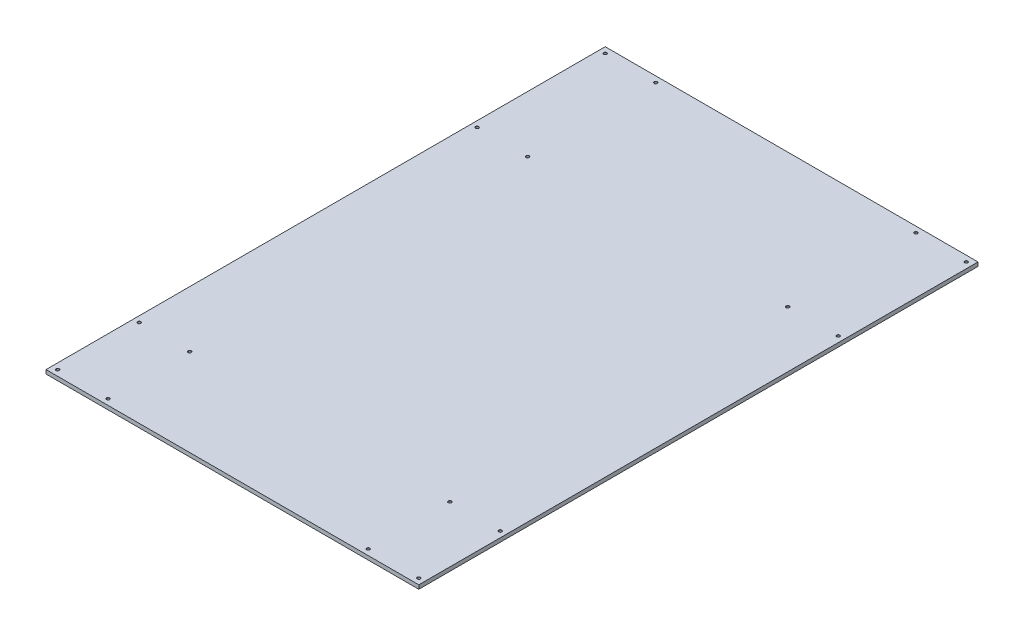
from build123d import *

# Parameters (mm, degrees)
SKETCH1_W                                 = 1219.2
SKETCH1_H                                 = 1828.8
BOSS_EXTRUDE1_DEPTH                       = 12.7
F_23_64_0_35938_DIAMETER_HOLE2_AT_2_COUNT = 2
F_23_64_0_35938_DIAMETER_HOLE2_AT_2_PITCH = 165.1
F_23_64_0_35938_DIAMETER_HOLE2_AT_3_COUNT = 2
F_23_64_0_35938_DIAMETER_HOLE2_AT_3_PITCH = 450.447355415
F_23_64_0_35938_DIAMETER_HOLE2_AT_4_COUNT = 2
F_23_64_0_35938_DIAMETER_HOLE2_AT_4_PITCH = 419.1
F_23_64_0_35938_DIAMETER_HOLE2_AT_5_COUNT = 2
F_23_64_0_35938_DIAMETER_HOLE2_AT_5_PITCH = 1524
F_23_64_0_35938_DIAMETER_HOLE2_AT_6_COUNT = 2
F_23_64_0_35938_DIAMETER_HOLE2_AT_6_PITCH = 1532.916830751
F_23_64_0_35938_DIAMETER_HOLE2_AT_7_COUNT = 2
F_23_64_0_35938_DIAMETER_HOLE2_AT_7_PITCH = 1798.29488683
F_23_64_0_35938_DIAMETER_HOLE2_AT_8_COUNT = 2
F_23_64_0_35938_DIAMETER_HOLE2_AT_8_PITCH = 1790.7


with BuildPart() as part:
    # Sketch1 → Boss-Extrude1 (new body)
    with BuildSketch(Plane(origin=(0, 0, 0), x_dir=(1, 0, 0), z_dir=(0, 1, 0))):
        Rectangle(SKETCH1_W, SKETCH1_H)
    extrude(amount=-BOSS_EXTRUDE1_DEPTH)

    # Sketch6 → 23_64 _0.35938_ Diameter Hole2 (revolve, cut)
    with BuildSketch(Plane(origin=(-590.55, 0, -895.35), x_dir=(0, 0, 1), z_dir=(1, 0, 0))):
        Polygon((0, 0), (0, 9.921875), (4.564126, 7.179471426), (4.564126, 0.635), (5.199126, 0), align=None)
    f_23_64_0_35938_diameter_hole2 = revolve(axis=Axis((-590.55, 6.35, -895.35), (0, -1, 0)), mode=Mode.SUBTRACT)

    # 23_64 _0.35938_ Diameter Hole2 at 2: 23_64 _0.35938_ Diameter Hole2 ×2
    with Locations(*[(i * F_23_64_0_35938_DIAMETER_HOLE2_AT_2_PITCH, 0, 0) for i in range(1, F_23_64_0_35938_DIAMETER_HOLE2_AT_2_COUNT)]):
        add(f_23_64_0_35938_diameter_hole2, mode=Mode.SUBTRACT)

    # 23_64 _0.35938_ Diameter Hole2 at 3: 23_64 _0.35938_ Diameter Hole2 ×2
    with Locations(*[Vector(0.3665245183824908, 0, 0.9304083928170915) * (i * F_23_64_0_35938_DIAMETER_HOLE2_AT_3_PITCH) for i in range(1, F_23_64_0_35938_DIAMETER_HOLE2_AT_3_COUNT)]):
        add(f_23_64_0_35938_diameter_hole2, mode=Mode.SUBTRACT)

    # 23_64 _0.35938_ Diameter Hole2 at 4: 23_64 _0.35938_ Diameter Hole2 ×2
    with Locations(*[(0, 0, i * F_23_64_0_35938_DIAMETER_HOLE2_AT_4_PITCH) for i in range(1, F_23_64_0_35938_DIAMETER_HOLE2_AT_4_COUNT)]):
        add(f_23_64_0_35938_diameter_hole2, mode=Mode.SUBTRACT)

    # 23_64 _0.35938_ Diameter Hole2 at 5: 23_64 _0.35938_ Diameter Hole2 ×2
    with Locations(*[(0, 0, i * F_23_64_0_35938_DIAMETER_HOLE2_AT_5_PITCH) for i in range(1, F_23_64_0_35938_DIAMETER_HOLE2_AT_5_COUNT)]):
        add(f_23_64_0_35938_diameter_hole2, mode=Mode.SUBTRACT)

    # 23_64 _0.35938_ Diameter Hole2 at 6: 23_64 _0.35938_ Diameter Hole2 ×2
    with Locations(*[Vector(0.1077031686833943, 0, 0.9941830955390242) * (i * F_23_64_0_35938_DIAMETER_HOLE2_AT_6_PITCH) for i in range(1, F_23_64_0_35938_DIAMETER_HOLE2_AT_6_COUNT)]):
        add(f_23_64_0_35938_diameter_hole2, mode=Mode.SUBTRACT)

    # 23_64 _0.35938_ Diameter Hole2 at 7: 23_64 _0.35938_ Diameter Hole2 ×2
    with Locations(*[Vector(0.09180919170103835, 0, 0.9957766176804926) * (i * F_23_64_0_35938_DIAMETER_HOLE2_AT_7_PITCH) for i in range(1, F_23_64_0_35938_DIAMETER_HOLE2_AT_7_COUNT)]):
        add(f_23_64_0_35938_diameter_hole2, mode=Mode.SUBTRACT)

    # 23_64 _0.35938_ Diameter Hole2 at 8: 23_64 _0.35938_ Diameter Hole2 ×2
    with Locations(*[(0, 0, i * F_23_64_0_35938_DIAMETER_HOLE2_AT_8_PITCH) for i in range(1, F_23_64_0_35938_DIAMETER_HOLE2_AT_8_COUNT)]):
        add(f_23_64_0_35938_diameter_hole2, mode=Mode.SUBTRACT)

    # Mirror1: 23_64 _0.35938_ Diameter Hole2 across plane
    add(f_23_64_0_35938_diameter_hole2.mirror(Plane(origin=(0, 0, 0), x_dir=(0, 0, 1), z_dir=(1, 0, 0))), mode=Mode.SUBTRACT)

    # Mirror1 copy 1 sketch → Mirror1 copy 1 (revolve, cut)
    with BuildSketch(Plane(origin=(425.45, 0, -895.35), x_dir=(0, 0, 1), z_dir=(-1, 0, 0))):
        Polygon((0, 0), (0, -9.921875), (4.564126, -7.179471426), (4.564126, -0.635), (5.199126, 0), align=None)
    revolve(axis=Axis((425.45, 6.35, -895.35), (0, 1, 0)), mode=Mode.SUBTRACT)

    # Mirror1 copy 2 sketch → Mirror1 copy 2 (revolve, cut)
    with BuildSketch(Plane(origin=(425.45, 0, -476.25), x_dir=(0, 0, 1), z_dir=(-1, 0, 0))):
        Polygon((0, 0), (0, -9.921875), (4.564126, -7.179471426), (4.564126, -0.635), (5.199126, 0), align=None)
    revolve(axis=Axis((425.45, 6.35, -476.25), (0, 1, 0)), mode=Mode.SUBTRACT)

    # Mirror1 copy 3 sketch → Mirror1 copy 3 (revolve, cut)
    with BuildSketch(Plane(origin=(590.55, 0, -476.25), x_dir=(0, 0, 1), z_dir=(-1, 0, 0))):
        Polygon((0, 0), (0, -9.921875), (4.564126, -7.179471426), (4.564126, -0.635), (5.199126, 0), align=None)
    revolve(axis=Axis((590.55, 6.35, -476.25), (0, 1, 0)), mode=Mode.SUBTRACT)

    # Mirror1 copy 4 sketch → Mirror1 copy 4 (revolve, cut)
    with BuildSketch(Plane(origin=(590.55, 0, 628.65), x_dir=(0, 0, 1), z_dir=(-1, 0, 0))):
        Polygon((0, 0), (0, -9.921875), (4.564126, -7.179471426), (4.564126, -0.635), (5.199126, 0), align=None)
    revolve(axis=Axis((590.55, 6.35, 628.65), (0, 1, 0)), mode=Mode.SUBTRACT)

    # Mirror1 copy 5 sketch → Mirror1 copy 5 (revolve, cut)
    with BuildSketch(Plane(origin=(425.45, 0, 628.65), x_dir=(0, 0, 1), z_dir=(-1, 0, 0))):
        Polygon((0, 0), (0, -9.921875), (4.564126, -7.179471426), (4.564126, -0.635), (5.199126, 0), align=None)
    revolve(axis=Axis((425.45, 6.35, 628.65), (0, 1, 0)), mode=Mode.SUBTRACT)

    # Mirror1 copy 6 sketch → Mirror1 copy 6 (revolve, cut)
    with BuildSketch(Plane(origin=(425.45, 0, 895.35), x_dir=(0, 0, 1), z_dir=(-1, 0, 0))):
        Polygon((0, 0), (0, -9.921875), (4.564126, -7.179471426), (4.564126, -0.635), (5.199126, 0), align=None)
    revolve(axis=Axis((425.45, 6.35, 895.35), (0, 1, 0)), mode=Mode.SUBTRACT)

    # Mirror1 copy 7 sketch → Mirror1 copy 7 (revolve, cut)
    with BuildSketch(Plane(origin=(590.55, 0, 895.35), x_dir=(0, 0, 1), z_dir=(-1, 0, 0))):
        Polygon((0, 0), (0, -9.921875), (4.564126, -7.179471426), (4.564126, -0.635), (5.199126, 0), align=None)
    revolve(axis=Axis((590.55, 6.35, 895.35), (0, 1, 0)), mode=Mode.SUBTRACT)


solid = part.part
